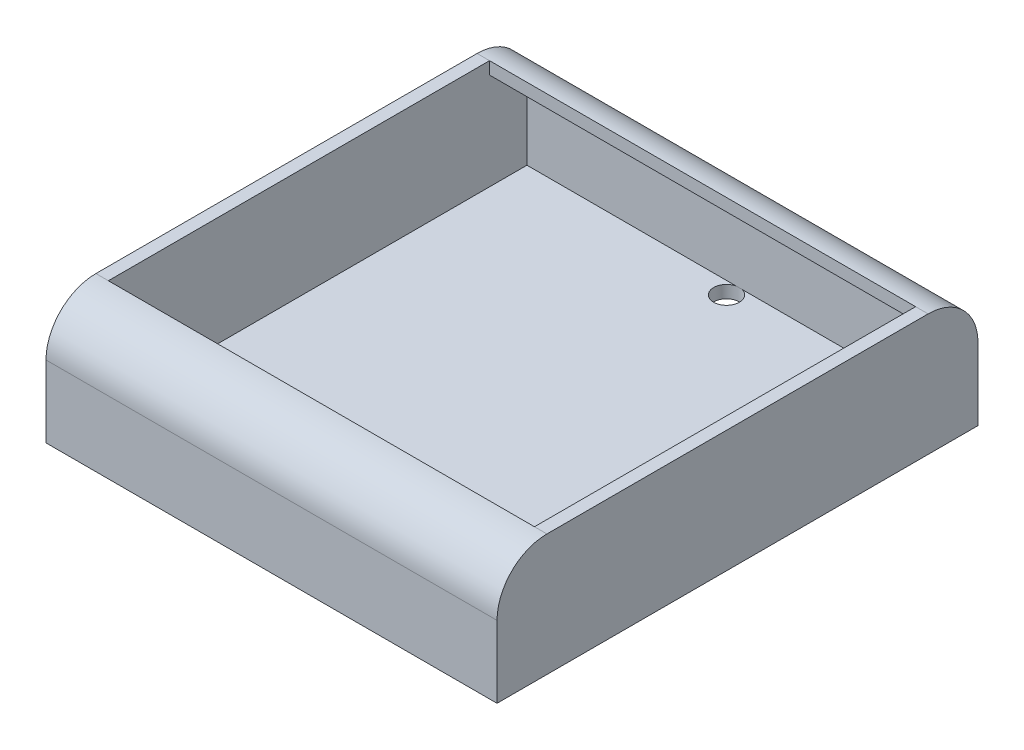
from build123d import *

# Parameters (mm, degrees)
SKETCH1_W                      = 57.404
SKETCH1_H                      = 61.214
BOSS_EXTRUDE1_DEPTH            = 1.5875
BOSS_EXTRUDE2_DEPTH            = 1.5875
BOSS_EXTRUDE3_DEPTH            = 54.229
BOSS_EXTRUDE4_DEPTH            = 1.5875
SKETCH6_W                      = 1.63195
SKETCH6_H                      = 1.5875
F_4_CLEARANCE_HOLE1_AT_2_COUNT = 2
F_4_CLEARANCE_HOLE1_AT_2_PITCH = 54.864


with BuildPart() as part:
    # Sketch1 → Boss-Extrude1 (new body)
    with BuildSketch(Plane(origin=(0, 0, 0), x_dir=(1, 0, 0), z_dir=(0, 1, 0))):
        with Locations((28.702, -30.607)):
            Rectangle(SKETCH1_W, SKETCH1_H)
    extrude(amount=BOSS_EXTRUDE1_DEPTH)

    # Sketch2 → Boss-Extrude2 (add)
    with BuildSketch(Plane(origin=(57.404, 0, 0), x_dir=(0, 0, -1), z_dir=(1, 0, 0))):
        with BuildLine():
            Line((-61.214, 1.5875), (0, 1.5875))
            Line((0, 1.5875), (0, 9.144))
            ThreePointArc((0, 9.144), (-1.859871939, 13.634128061), (-6.35, 15.494))
            Line((-6.35, 15.494), (-54.864, 15.494))
            ThreePointArc((-54.864, 15.494), (-59.354128061, 13.634128061), (-61.214, 9.144))
            Line((-61.214, 9.144), (-61.214, 1.5875))
        make_face()
    extrude(amount=-BOSS_EXTRUDE2_DEPTH)

    # Sketch3 → Boss-Extrude3 (add)
    with BuildSketch(Plane.ZY.offset(-55.8165)):
        with BuildLine():
            Line((1.5875, 1.5875), (1.5875, 3.175))
            Line((1.5875, 3.175), (1.5875, 9.144))
            ThreePointArc((1.5875, 9.144), (2.982403955, 12.511596045), (6.35, 13.9065))
            Line((6.35, 13.9065), (6.35, 15.494))
            ThreePointArc((6.35, 15.494), (1.859871939, 13.634128061), (0, 9.144))
            Line((0, 9.144), (0, 1.5875))
            Line((0, 1.5875), (1.5875, 1.5875))
        make_face()
        with BuildLine():
            Line((59.6265, 9.144), (59.6265, 3.175))
            Line((59.6265, 3.175), (59.6265, 1.5875))
            Line((59.6265, 1.5875), (61.214, 1.5875))
            Line((61.214, 1.5875), (61.214, 9.144))
            ThreePointArc((61.214, 9.144), (59.354128061, 13.634128061), (54.864, 15.494))
            Line((54.864, 15.494), (54.864, 13.9065))
            ThreePointArc((54.864, 13.9065), (58.231596045, 12.511596045), (59.6265, 9.144))
        make_face()
    extrude(amount=BOSS_EXTRUDE3_DEPTH)

    # Sketch4 → Boss-Extrude4 (add)
    with BuildSketch(Plane.ZY.offset(-1.5875)):
        with BuildLine():
            Line((0, 0), (61.214, 0))
            Line((61.214, 0), (61.214, 9.144))
            ThreePointArc((61.214, 9.144), (59.354128061, 13.634128061), (54.864, 15.494))
            Line((54.864, 15.494), (6.35, 15.494))
            ThreePointArc((6.35, 15.494), (1.859871939, 13.634128061), (0, 9.144))
            Line((0, 9.144), (0, 0))
        make_face()
    extrude(amount=BOSS_EXTRUDE4_DEPTH)

    # Sketch6 → #4 Clearance Hole1 (revolve, cut)
    with BuildSketch(Plane(origin=(28.575, 1.5875, 58.039), x_dir=(0, 0, 1), z_dir=(1, 0, 0))):
        with Locations((0.815975, 0.79375)):
            Rectangle(SKETCH6_W, SKETCH6_H)
    f_4_clearance_hole1 = revolve(axis=Axis((28.575, 7.9375, 58.039), (0, -1, 0)), mode=Mode.SUBTRACT)

    # #4 Clearance Hole1 at 2: #4 Clearance Hole1 ×2
    with Locations(*[(0, 0, -i * F_4_CLEARANCE_HOLE1_AT_2_PITCH) for i in range(1, F_4_CLEARANCE_HOLE1_AT_2_COUNT)]):
        add(f_4_clearance_hole1, mode=Mode.SUBTRACT)


solid = part.part
